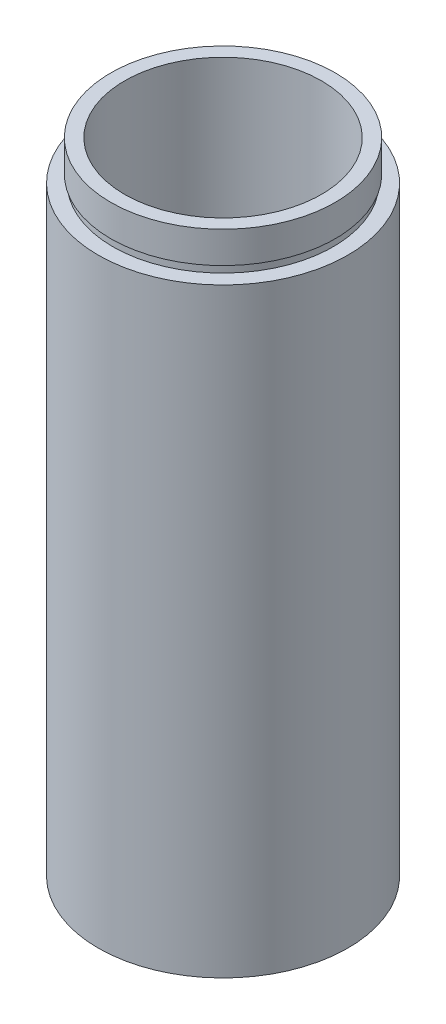
from build123d import *


with BuildPart() as part:
    # 草图1 → 旋转1 (revolve)
    with BuildSketch(Plane.XY, mode=Mode.PRIVATE) as revolve_1_sk:
        Polygon((14.25, 0), (14.25, 4.5), (14.35, 4.5), (14.35, 5.5), (12.5, 5.5), (12.5, 81.2), (14.25, 81.2), (14.25, 77.2), (14, 77.2), (14, 76.2), (15.85, 76.2), (15.85, 0), align=None)
    revolve(revolve_1_sk.sketch.rotate(Axis((0, 161.376166943, 0), (0, -1, 0)), 90), axis=Axis((0, 161.376166943, 0), (0, -1, 0)))  # turned: the seam where the file's is


solid = part.part
